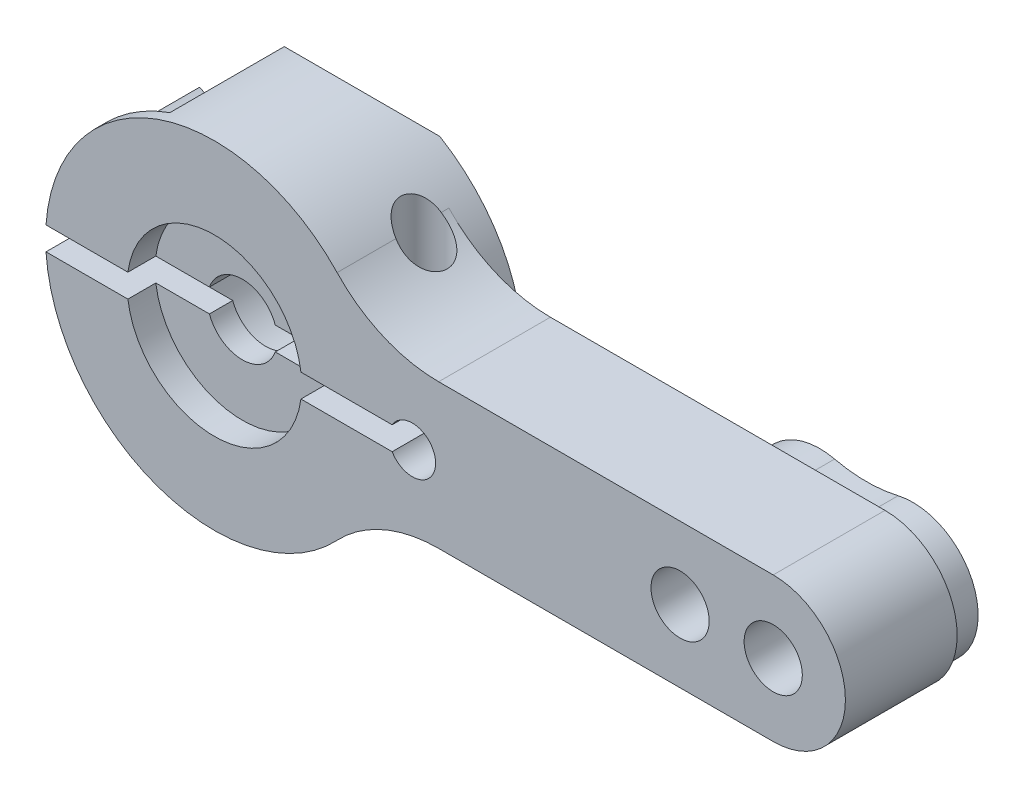
from build123d import *

# Parameters (mm, degrees)
SKETCH_1_R               = 1.25
EXTRUDE_1_DEPTH          = 6
CUT_EXTRUDE_1_DEPTH      = 1.2
SKETCH_1_4_R             = 2.75
CUT_EXTRUDE_2_DEPTH      = 3.8
CUT_EXTRUDE_START        = 6
SKETCH_1_5_R             = 3.75
CUT_EXTRUDE_3_DEPTH      = 1.2
FILLET_1_R               = 6
SKETCH_2_R               = 3
CUT_EXTRUDE_4_DEPTH      = 5.5
SKETCH_3_R               = 1
CUT_EXTRUDE_5_DEPTH      = 8.25
CUT_EXTRUDE_5_DEPTH_BACK = 8.25
CUT_EXTRUDE_6_DEPTH      = 28.1
CUT_EXTRUDE_6_DEPTH_BACK = 8.232738171


with BuildPart() as part:
    # Эскиз1 → Бобышка-Вытянуть1 (new body)
    with BuildSketch(Plane.XY):
        with BuildLine():
            ThreePointArc((24, -3.1), (27.1, 0), (24, 3.1))
            Line((24, 3.1), (6.553815682, 3.1))
            ThreePointArc((6.553815682, 3.1), (7.014789099, 1.831729757), (7.232738071, 0.5))
            Line((7.232738071, 0.5), (7.633974596, 0.5))
            ThreePointArc((7.633974596, 0.5), (8.758819045, 0.965925826), (9.5, 0))
            ThreePointArc((9.5, 0), (8.758819045, -0.965925826), (7.633974596, -0.5))
            Line((7.633974596, -0.5), (7.232738071, -0.5))
            ThreePointArc((7.232738071, -0.5), (7.014789099, -1.831729757), (6.553815682, -3.1))
            Line((6.553815682, -3.1), (24, -3.1))
        make_face()
        with BuildLine():
            ThreePointArc((23.363636364, 2.726727218), (26.8, 0), (23.363636364, -2.726727218))
            ThreePointArc((23.363636364, -2.726727218), (22, -2.569714114), (20.636363636, -2.726727218))
            ThreePointArc((20.636363636, -2.726727218), (17.2, 0), (20.636363636, 2.726727218))
            ThreePointArc((20.636363636, 2.726727218), (22, 2.569714114), (23.363636364, 2.726727218))
        make_face(mode=Mode.SUBTRACT)
        with BuildLine():
            ThreePointArc((20.636363636, 2.726727218), (22, 2.569714114), (23.363636364, 2.726727218))
            ThreePointArc((23.363636364, 2.726727218), (26.8, 0), (23.363636364, -2.726727218))
            ThreePointArc((23.363636364, -2.726727218), (22, -2.569714114), (20.636363636, -2.726727218))
            ThreePointArc((20.636363636, -2.726727218), (17.2, 0), (20.636363636, 2.726727218))
        make_face()
        with Locations((20, 0)):
            Circle(SKETCH_1_R, mode=Mode.SUBTRACT)
        with Locations((24, 0)):
            Circle(SKETCH_1_R, mode=Mode.SUBTRACT)
        with BuildLine():
            ThreePointArc((7.232738071, 0.5), (7.014789099, 1.831729757), (6.553815682, 3.1))
            ThreePointArc((6.553815682, 3.1), (-1.343589931, 7.124413386), (-7.232738071, 0.5))
            Line((-7.232738071, 0.5), (-3.716517187, 0.5))
            ThreePointArc((-3.716517187, 0.5), (0, 3.75), (3.716517187, 0.5))
            Line((3.716517187, 0.5), (7.232738071, 0.5))
        make_face()
        with BuildLine():
            ThreePointArc((3.716517187, 0.5), (0, 3.75), (-3.716517187, 0.5))
            Line((-3.716517187, 0.5), (-2.704163457, 0.5))
            ThreePointArc((-2.704163457, 0.5), (0, 2.75), (2.704163457, 0.5))
            Line((2.704163457, 0.5), (3.716517187, 0.5))
        make_face()
        with BuildLine():
            ThreePointArc((2.704163457, 0.5), (0, 2.75), (-2.704163457, 0.5))
            Line((-2.704163457, 0.5), (-1.414213562, 0.5))
            ThreePointArc((-1.414213562, 0.5), (0, 1.5), (1.414213562, 0.5))
            Line((1.414213562, 0.5), (2.704163457, 0.5))
        make_face()
        with BuildLine():
            ThreePointArc((-7.232738071, -0.5), (-1.343589931, -7.124413386), (6.553815682, -3.1))
            ThreePointArc((6.553815682, -3.1), (7.014789099, -1.831729757), (7.232738071, -0.5))
            Line((7.232738071, -0.5), (3.716517187, -0.5))
            ThreePointArc((3.716517187, -0.5), (0, -3.75), (-3.716517187, -0.5))
            Line((-3.716517187, -0.5), (-7.232738071, -0.5))
        make_face()
        with BuildLine():
            Line((-2.704163457, -0.5), (-3.716517187, -0.5))
            ThreePointArc((-3.716517187, -0.5), (0, -3.75), (3.716517187, -0.5))
            Line((3.716517187, -0.5), (2.704163457, -0.5))
            ThreePointArc((2.704163457, -0.5), (0, -2.75), (-2.704163457, -0.5))
        make_face()
        with BuildLine():
            Line((-1.414213562, -0.5), (-2.704163457, -0.5))
            ThreePointArc((-2.704163457, -0.5), (0, -2.75), (2.704163457, -0.5))
            Line((2.704163457, -0.5), (1.414213562, -0.5))
            ThreePointArc((1.414213562, -0.5), (0, -1.5), (-1.414213562, -0.5))
        make_face()
    extrude(amount=EXTRUDE_1_DEPTH)

    # Эскиз1<3> → Вырез-Вытянуть1 (cut)
    with BuildSketch(Plane.XY):
        with BuildLine():
            ThreePointArc((24, -3.1), (27.1, 0), (24, 3.1))
            Line((24, 3.1), (6.553815682, 3.1))
            ThreePointArc((6.553815682, 3.1), (7.014789099, 1.831729757), (7.232738071, 0.5))
            Line((7.232738071, 0.5), (7.633974596, 0.5))
            ThreePointArc((7.633974596, 0.5), (8.758819045, 0.965925826), (9.5, 0))
            ThreePointArc((9.5, 0), (8.758819045, -0.965925826), (7.633974596, -0.5))
            Line((7.633974596, -0.5), (7.232738071, -0.5))
            ThreePointArc((7.232738071, -0.5), (7.014789099, -1.831729757), (6.553815682, -3.1))
            Line((6.553815682, -3.1), (24, -3.1))
        make_face()
        with BuildLine():
            ThreePointArc((23.363636364, 2.726727218), (26.8, 0), (23.363636364, -2.726727218))
            ThreePointArc((23.363636364, -2.726727218), (22, -2.569714114), (20.636363636, -2.726727218))
            ThreePointArc((20.636363636, -2.726727218), (17.2, 0), (20.636363636, 2.726727218))
            ThreePointArc((20.636363636, 2.726727218), (22, 2.569714114), (23.363636364, 2.726727218))
        make_face(mode=Mode.SUBTRACT)
    extrude(amount=CUT_EXTRUDE_1_DEPTH, mode=Mode.SUBTRACT)

    # Эскиз1<4> → Вырез-Вытянуть2 (cut)
    with BuildSketch(Plane.XY):
        Circle(SKETCH_1_4_R)
    extrude(amount=CUT_EXTRUDE_2_DEPTH, mode=Mode.SUBTRACT)

    # Эскиз1<5> → Вырез-Вытянуть3 (cut)
    with BuildSketch(Plane.XY.offset(CUT_EXTRUDE_START)):
        Circle(SKETCH_1_5_R)
    extrude(amount=-CUT_EXTRUDE_3_DEPTH, mode=Mode.SUBTRACT)

    # Скругление1
    fillet_1_edges = [part.edges().sort_by_distance(p)[0] for p in [
        (6.553815682, 3.1, 3.6),
        (6.553815682, -3.1, 3.6),
    ]]
    fillet(fillet_1_edges, radius=FILLET_1_R)

    # Эскиз2 → Вырез-Вытянуть4 (cut)
    with BuildSketch(Plane.XY):
        with Locations((5.099019514, -5.5)):
            Circle(SKETCH_2_R)
        with Locations((-5.099019514, 5.5)):
            Circle(SKETCH_2_R)
    extrude(amount=CUT_EXTRUDE_4_DEPTH, mode=Mode.SUBTRACT)

    # Эскиз3 → Вырез-Вытянуть5 (cut, two sides)
    with BuildSketch(Plane(origin=(0, 0, 0), x_dir=(1, 0, 0), z_dir=(0, 1, 0))) as cut_extrude_5_sk:
        with Locations((5.5, -2.5)):
            Circle(SKETCH_3_R)
        with Locations((-5.5, -2.5)):
            Circle(SKETCH_3_R)
    extrude(amount=CUT_EXTRUDE_5_DEPTH, mode=Mode.SUBTRACT)
    extrude(cut_extrude_5_sk.sketch, amount=-CUT_EXTRUDE_5_DEPTH_BACK, mode=Mode.SUBTRACT)

    # Эскиз4 → Вырез-Вытянуть6 (cut, two sides)
    with BuildSketch(Plane(origin=(0, 0, 0), x_dir=(0, 0, -1), z_dir=(1, 0, 0))) as cut_extrude_6_sk:
        Polygon((0, -6.25), (-1, -7.25), (0, -7.25), align=None)
        Polygon((0, 7.25), (0, 6.25), (-1, 7.25), align=None)
    extrude(amount=CUT_EXTRUDE_6_DEPTH, mode=Mode.SUBTRACT)
    extrude(cut_extrude_6_sk.sketch, amount=-CUT_EXTRUDE_6_DEPTH_BACK, mode=Mode.SUBTRACT)


solid = part.part
